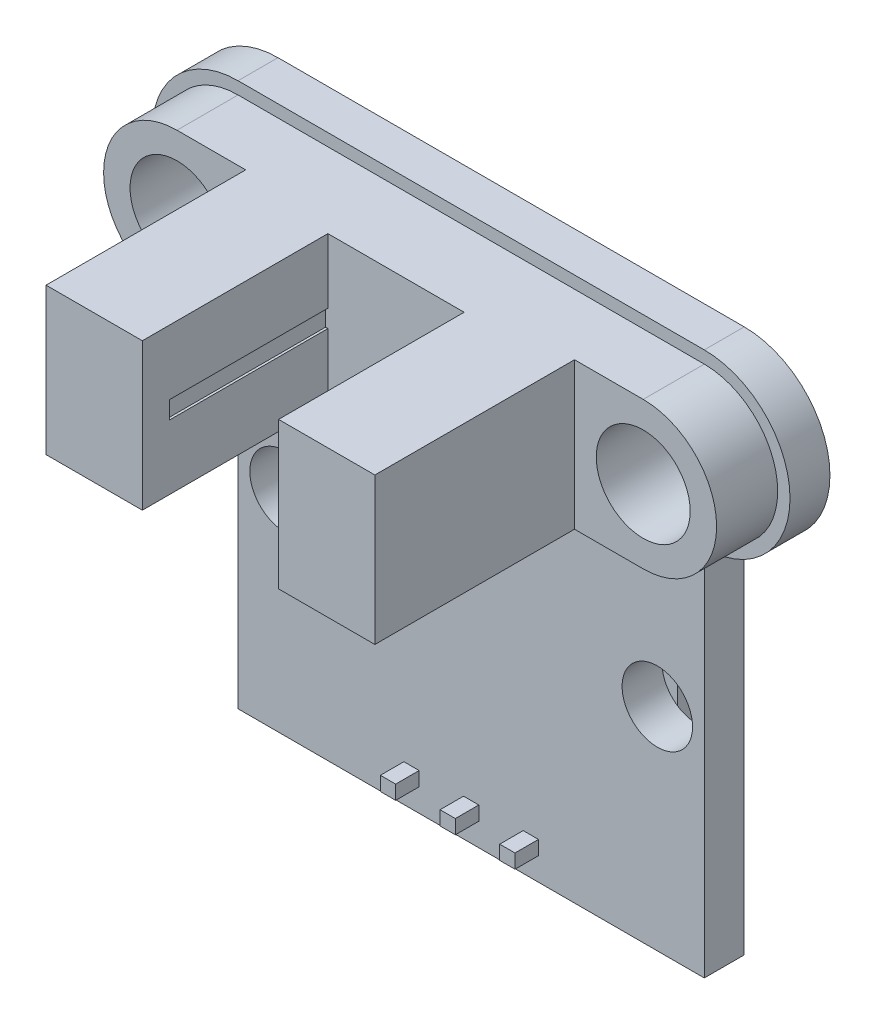
from build123d import *

# Parameters (mm, degrees)
IZIM1_R                     = 2
IZIM1_R_2                   = 1.5
Y_KSEKLIK_EKSTR_ZYON1_DEPTH = 1.7
IZIM2_R                     = 2
Y_KSEKLIK_EKSTR_ZYON2_DEPTH = 2.6
IZIM3_W                     = 4.100055298
IZIM3_H                     = 6.25
Y_KSEKLIK_EKSTR_ZYON3_DEPTH = 8.5
IZIM4_W                     = 5.8
IZIM4_H                     = 6.25
Y_KSEKLIK_EKSTR_ZYON4_DEPTH = 0.6
Y_KSEKLIK_EKSTR_ZYON6_DEPTH = 2.54
IZIM6_W                     = 19.85
IZIM6_H                     = 1.7
Y_KSEKLIK_EKSTR_ZYON7_DEPTH = 0.01
IZIM7_W                     = 6.75
IZIM7_H                     = 0.75
KES_EKSTR_ZYON1_DEPTH       = 5.9
KES_EKSTR_ZYON1_DEPTH_BACK  = 0.1
IZIM8_W                     = 0.664910116
IZIM8_H                     = 0.664910116
IZIM11_W                    = 0.65
IZIM11_H                    = 0.6
Y_KSEKLIK_EKSTR_ZYON8_DEPTH = 1
Y_KSEKLIK_EKSTR_ZYON9_DEPTH = 1.5


with BuildPart() as part:
    # Çizim1 → Yükseklik-Ekstrüzyon1 (new body)
    with BuildSketch(Plane.XY):
        with BuildLine():
            Line((-9.925, -11.575), (9.925, -11.575))
            Line((9.925, -11.575), (9.925, 4.275))
            ThreePointArc((9.925, 4.275), (13.575, 7.925), (9.925, 11.575))
            Line((9.925, 11.575), (-9.925, 11.575))
            ThreePointArc((-9.925, 11.575), (-13.575, 7.925), (-9.925, 4.275))
            Line((-9.925, 4.275), (-9.925, -11.575))
        make_face()
        with Locations((9.925, 7.925)):
            Circle(IZIM1_R, mode=Mode.SUBTRACT)
        with Locations((-9.925, 7.925)):
            Circle(IZIM1_R, mode=Mode.SUBTRACT)
        with Locations((7.925, -2.575)):
            Circle(IZIM1_R_2, mode=Mode.SUBTRACT)
        with Locations((-7.925, -2.575)):
            Circle(IZIM1_R_2, mode=Mode.SUBTRACT)
    extrude(amount=Y_KSEKLIK_EKSTR_ZYON1_DEPTH)

    # Çizim2 → Yükseklik-Ekstrüzyon2 (add)
    with BuildSketch(Plane.XY.offset(1.7)):
        with BuildLine():
            Line((-9.925, 11.05), (9.925, 11.05))
            ThreePointArc((9.925, 11.05), (13.05, 7.925), (9.925, 4.8))
            Line((9.925, 4.8), (-9.925, 4.8))
            ThreePointArc((-9.925, 4.8), (-13.05, 7.925), (-9.925, 11.05))
        make_face()
        with Locations((-9.925, 7.925)):
            Circle(IZIM2_R, mode=Mode.SUBTRACT)
        with Locations((9.925, 7.925)):
            Circle(IZIM2_R, mode=Mode.SUBTRACT)
    extrude(amount=Y_KSEKLIK_EKSTR_ZYON2_DEPTH)

    # Çizim3 → Yükseklik-Ekstrüzyon3 (add)
    with BuildSketch(Plane.XY.offset(4.3)):
        with Locations((4.950027649, 7.925)):
            Rectangle(IZIM3_W, IZIM3_H)
        with Locations((-4.950027649, 7.925)):
            Rectangle(IZIM3_W, IZIM3_H)
    extrude(amount=Y_KSEKLIK_EKSTR_ZYON3_DEPTH)

    # Çizim4 → Yükseklik-Ekstrüzyon4 (add)
    with BuildSketch(Plane.XY.offset(4.3)):
        with Locations((0, 7.925)):
            Rectangle(IZIM4_W, IZIM4_H)
    extrude(amount=Y_KSEKLIK_EKSTR_ZYON4_DEPTH)

    # Çizim5 → Yükseklik-Ekstrüzyon6 (add)
    with BuildSketch(Plane(origin=(0, 0, 0), x_dir=(-1, 0, 0), z_dir=(0, 0, -1))):
        Polygon((-1.27, -11.325), (-1.27, -9.285), (-1.52, -9.035), (-3.56, -9.035), (-3.81, -9.285), (-3.81, -11.325), (-3.56, -11.575), (-1.52, -11.575), align=None)
        Polygon((1.27, -9.285), (1.02, -9.035), (-1.02, -9.035), (-1.27, -9.285), (-1.27, -11.325), (-1.02, -11.575), (1.02, -11.575), (1.27, -11.325), align=None)
        Polygon((1.52, -9.035), (1.27, -9.285), (1.27, -11.325), (1.52, -11.575), (3.56, -11.575), (3.81, -11.325), (3.81, -9.285), (3.56, -9.035), align=None)
    extrude(amount=Y_KSEKLIK_EKSTR_ZYON6_DEPTH)

    # Çizim6 → Yükseklik-Ekstrüzyon7 (add)
    with BuildSketch(Plane.XZ.offset(11.575)):
        with Locations((0, 0.85)):
            Rectangle(IZIM6_W, IZIM6_H)
    extrude(amount=Y_KSEKLIK_EKSTR_ZYON7_DEPTH)

    # Çizim7 → Kes-Ekstrüzyon1 (cut, two sides)
    with BuildSketch(Plane.ZY.offset(-2.9)) as kes_ekstr_zyon1_sk:
        with Locations((8.275, 7.925)):
            Rectangle(IZIM7_W, IZIM7_H)
    extrude(amount=KES_EKSTR_ZYON1_DEPTH, mode=Mode.SUBTRACT)
    extrude(kes_ekstr_zyon1_sk.sketch, amount=-KES_EKSTR_ZYON1_DEPTH_BACK, mode=Mode.SUBTRACT)

    # Süpür1: sweep along a path in Çizim9
    with BuildLine(Plane(origin=(0, 0, 0), x_dir=(0, 0, -1), z_dir=(1, 0, 0))) as s_p_r1_path:
        Line((2.54, -10.305), (4.04, -10.305))
        ThreePointArc((4.04, -10.305), (4.393553391, -10.158553391), (4.54, -9.805))
        Line((4.54, -9.805), (4.54, -3.305))
    # Çizim8 → Süpür1 (sweep)
    with BuildSketch(Plane(origin=(0, 0, -2.54), x_dir=(-1, 0, 0), z_dir=(0, 0, -1))):
        with Locations((2.54, -10.305)):
            Rectangle(IZIM8_W, IZIM8_H)
        with Locations((0, -10.305)):
            Rectangle(IZIM8_W, IZIM8_H)
        with Locations((-2.54, -10.305)):
            Rectangle(IZIM8_W, IZIM8_H)
    sweep(path=s_p_r1_path.line)

    # Çizim11 → Yükseklik-Ekstrüzyon8 (add)
    with BuildSketch(Plane.XY.offset(1.7)):
        with Locations((-2.54, -10.305)):
            Rectangle(IZIM11_W, IZIM11_H)
        with Locations((0, -10.305)):
            Rectangle(IZIM11_W, IZIM11_H)
        with Locations((2.54, -10.305)):
            Rectangle(IZIM11_W, IZIM11_H)
    extrude(amount=Y_KSEKLIK_EKSTR_ZYON8_DEPTH)

    # Çizim12 → Yükseklik-Ekstrüzyon9 (add)
    with BuildSketch(Plane(origin=(0, 0, 0), x_dir=(-1, 0, 0), z_dir=(0, 0, -1))):
        Polygon((-3.925, -2.575), (-3.925, -0.075), (-0.175, -0.075), (-0.175, -5.075), (-3.925, -5.075), align=None)
    extrude(amount=Y_KSEKLIK_EKSTR_ZYON9_DEPTH)


solid = part.part
